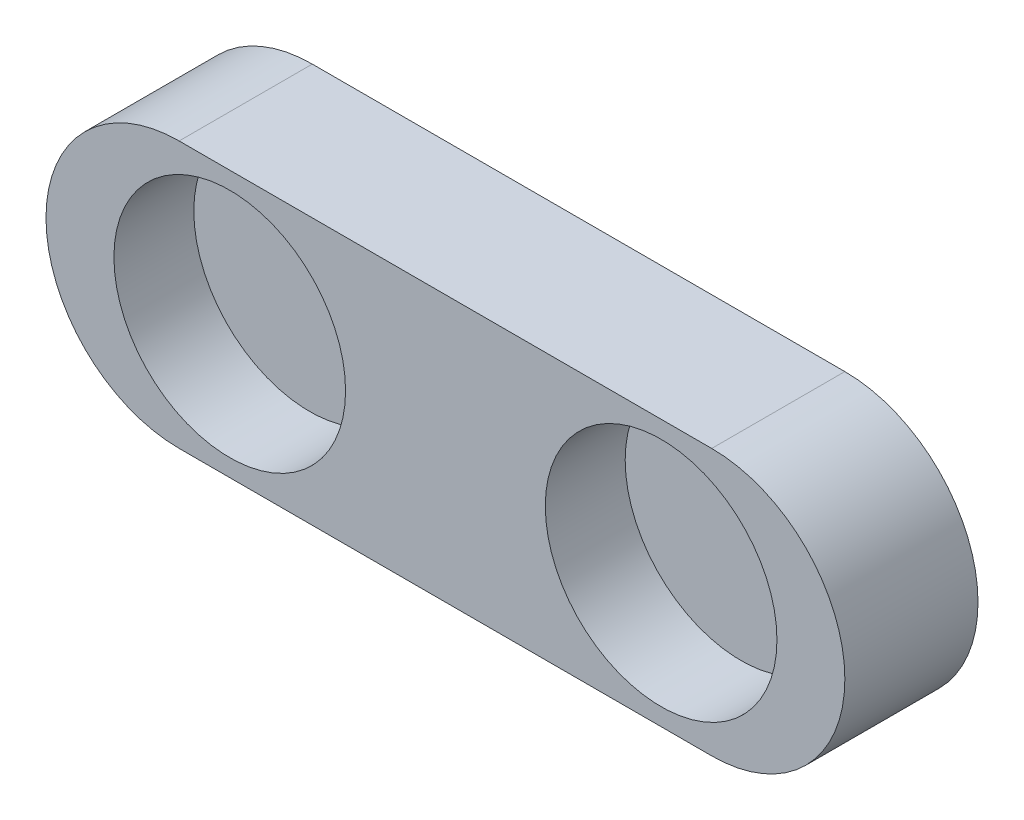
from build123d import *

# Parameters (mm, degrees)
BOSS_EXTRUDE1_DEPTH = 12.7
SKETCH2_R           = 11.049
CUT_EXTRUDE1_DEPTH  = 7.62


with BuildPart() as part:
    # Sketch1 → Boss-Extrude1 (new body)
    with BuildSketch(Plane.XY):
        with BuildLine():
            Line((0, 0), (50.8, 0))
            ThreePointArc((50.8, 0), (63.5, 12.7), (50.8, 25.4))
            Line((50.8, 25.4), (0, 25.4))
            ThreePointArc((0, 25.4), (-12.7, 12.7), (0, 0))
        make_face()
    extrude(amount=BOSS_EXTRUDE1_DEPTH)

    # Sketch2 → Cut-Extrude1 (cut)
    with BuildSketch(Plane.XY.offset(12.7)):
        with Locations((4.826, 12.7)):
            Circle(SKETCH2_R)
        with Locations((45.974, 12.7)):
            Circle(SKETCH2_R)
    extrude(amount=-CUT_EXTRUDE1_DEPTH, mode=Mode.SUBTRACT)


solid = part.part
